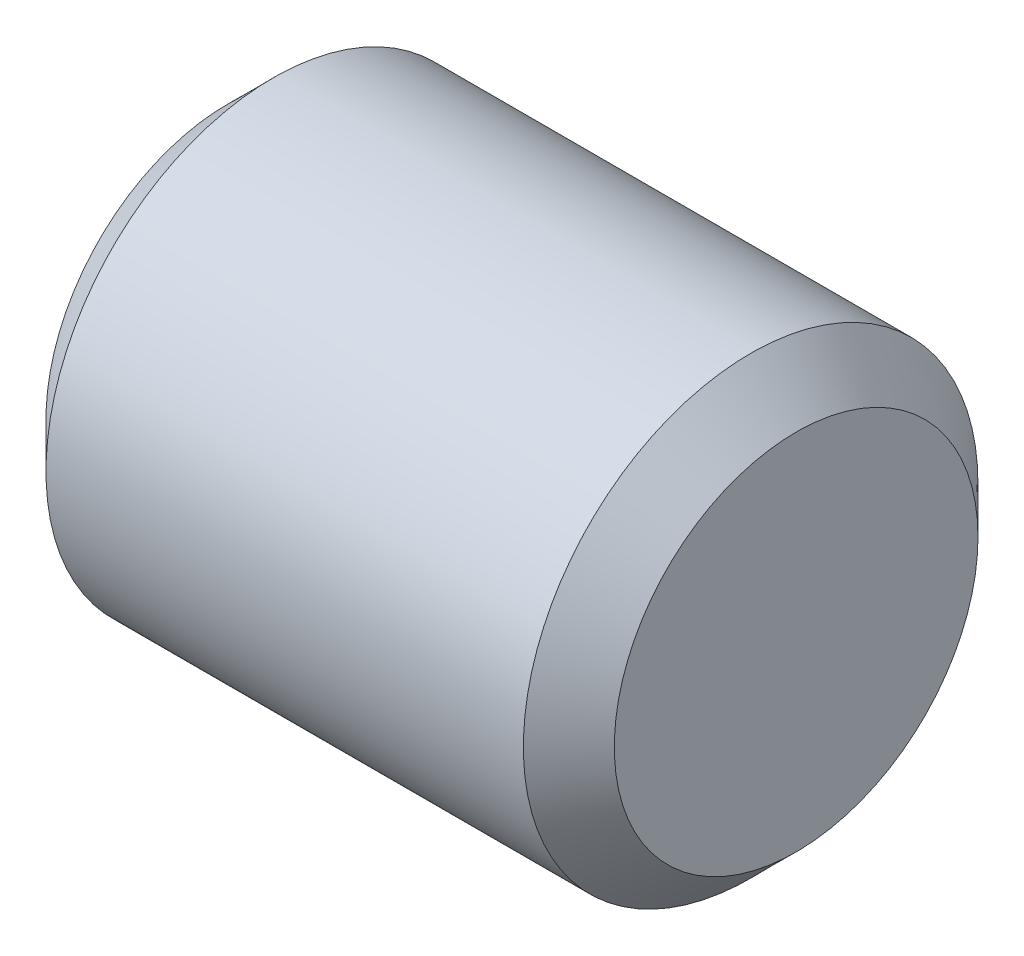
from build123d import *

# Parameters (mm, degrees)
SKETCH2_R           = 3.175
EXTRUDE1_DEPTH      = 3.96875
EXTRUDE1_DEPTH_BACK = 3.96875
CHAMFER1_SIZE       = 0.635


with BuildPart() as part:
    # Sketch2 → Extrude1 (new body, two sides)
    with BuildSketch(Plane(origin=(0, 0, 0), x_dir=(0, 0, -1), z_dir=(1, 0, 0))) as extrude1_sk:
        Circle(SKETCH2_R)
    extrude(amount=EXTRUDE1_DEPTH)
    extrude(extrude1_sk.sketch, amount=-EXTRUDE1_DEPTH_BACK)

    # Chamfer1
    chamfer1_edges = [part.edges().sort_by_distance(p)[0] for p in [
        (-3.96875, 0, 3.175),
        (3.96875, 0, 3.175),
    ]]
    chamfer(chamfer1_edges, length=CHAMFER1_SIZE)


solid = part.part
